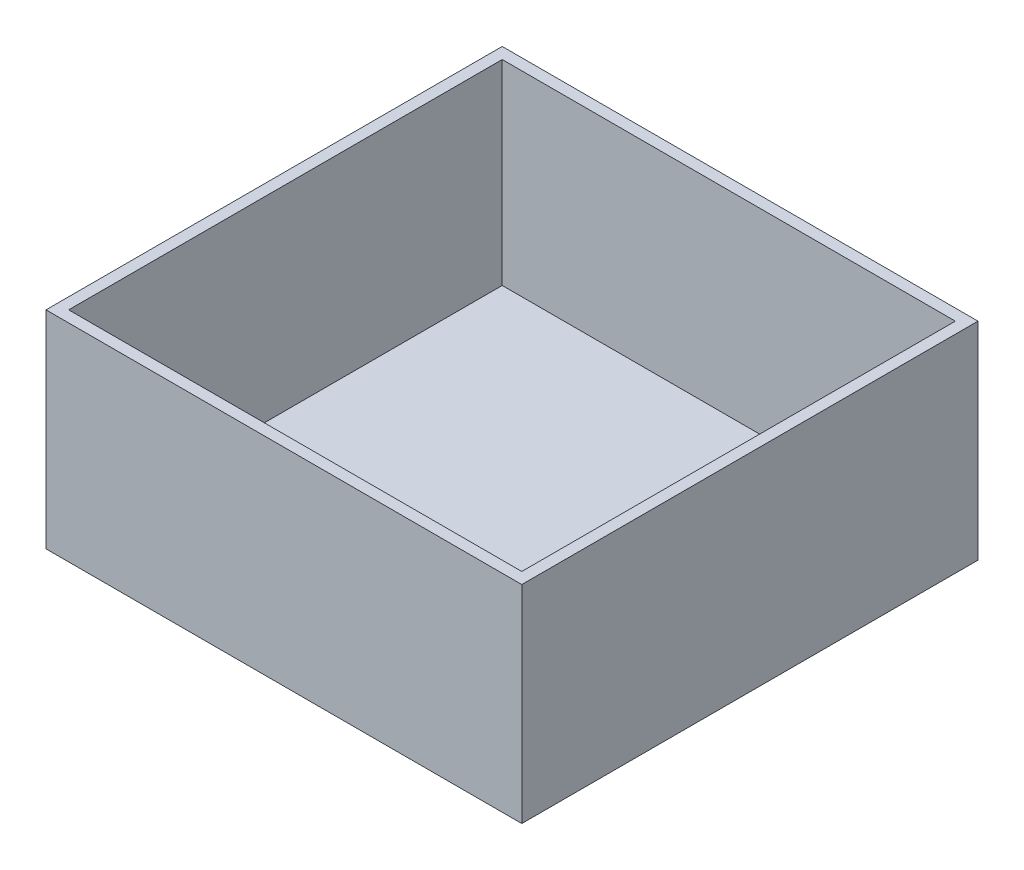
from build123d import *

# Parameters (mm, degrees)
SKETCH1_W           = 117.348
SKETCH1_H           = 112.522
BOSS_EXTRUDE1_DEPTH = 2.794
SKETCH3_W           = 114.554
SKETCH3_H           = 2.794
BOSS_EXTRUDE2_DEPTH = 48.26
LPATTERN1_COUNT     = 2
LPATTERN1_PITCH     = 109.728
SKETCH4_W           = 2.794
SKETCH4_H           = 106.934
BOSS_EXTRUDE3_DEPTH = 48.26
SKETCH6_W           = 2.794
SKETCH6_H           = 112.522
BOSS_EXTRUDE4_DEPTH = 48.26


with BuildPart() as part:
    # Sketch1 → Boss-Extrude1 (new body)
    with BuildSketch(Plane(origin=(0, 0, 0), x_dir=(1, 0, 0), z_dir=(0, 1, 0))):
        with Locations((58.674, 56.261)):
            Rectangle(SKETCH1_W, SKETCH1_H)
    extrude(amount=BOSS_EXTRUDE1_DEPTH)

    # Sketch3 → Boss-Extrude2 (add)
    with BuildSketch(Plane(origin=(0, 2.794, 0), x_dir=(1, 0, 0), z_dir=(0, 1, 0))):
        with Locations((57.277, 1.397)):
            Rectangle(SKETCH3_W, SKETCH3_H)
    boss_extrude2 = extrude(amount=BOSS_EXTRUDE2_DEPTH)

    # LPattern1: Boss-Extrude2 ×2
    with Locations(*[(0, 0, -i * LPATTERN1_PITCH) for i in range(1, LPATTERN1_COUNT)]):
        add(boss_extrude2)

    # Sketch4 → Boss-Extrude3 (add)
    with BuildSketch(Plane(origin=(0, 2.794, 0), x_dir=(1, 0, 0), z_dir=(0, 1, 0))):
        with Locations((1.397, 56.261)):
            Rectangle(SKETCH4_W, SKETCH4_H)
    extrude(amount=BOSS_EXTRUDE3_DEPTH)

    # Sketch6 → Boss-Extrude4 (add)
    with BuildSketch(Plane(origin=(0, 2.794, 0), x_dir=(1, 0, 0), z_dir=(0, 1, 0))):
        with Locations((115.951, 56.261)):
            Rectangle(SKETCH6_W, SKETCH6_H)
    extrude(amount=BOSS_EXTRUDE4_DEPTH)


solid = part.part
